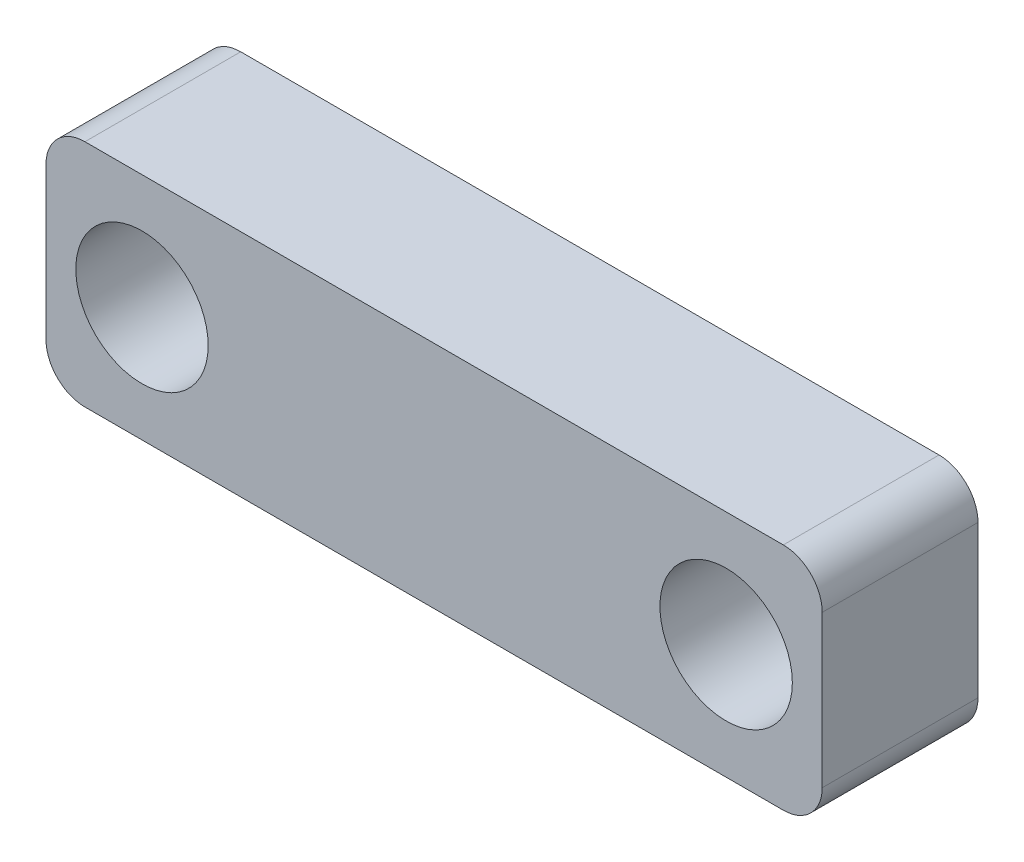
from build123d import *

# Parameters (mm, degrees)
SKETCH2_W                = 19.932631385
SKETCH2_H                = 5.9
BOSS_EXTRUDE1_DEPTH      = 4
FILLET1_R                = 1
M3_CLEARANCE_HOLE1_D     = 3.4
M3_CLEARANCE_HOLE1_DEPTH = 16.5
M3_CLEARANCE_HOLE1_TIP   = 1.021463052


with BuildPart() as part:
    # Sketch2 → Boss-Extrude1 (new body)
    with BuildSketch(Plane.XY.offset(133.365661293)):
        with Locations((-21.255805031, 37.989811256)):
            Rectangle(SKETCH2_W, SKETCH2_H)
    extrude(amount=BOSS_EXTRUDE1_DEPTH)

    # Fillet1
    fillet1_edges = [part.edges().sort_by_distance(p)[0] for p in [
        (-31.222120723, 40.939811256, 135.365661293),
        (-11.289489338, 40.939811256, 135.365661293),
        (-11.289489338, 35.039811256, 135.365661293),
        (-31.222120723, 35.039811256, 135.365661293),
    ]]
    fillet(fillet1_edges, radius=FILLET1_R)

    # M3 Clearance Hole1
    with Locations(Plane.XY.offset(137.365661293)):
        with Locations((-28.757120723, 37.989811256), (-13.757120723, 37.989811256)):
            Hole(M3_CLEARANCE_HOLE1_D / 2, depth=M3_CLEARANCE_HOLE1_DEPTH)
            with Locations((0, 0, -(M3_CLEARANCE_HOLE1_DEPTH + M3_CLEARANCE_HOLE1_TIP / 2))):  # 118° drill point
                Cone(0, M3_CLEARANCE_HOLE1_D / 2, M3_CLEARANCE_HOLE1_TIP, mode=Mode.SUBTRACT)


solid = part.part
